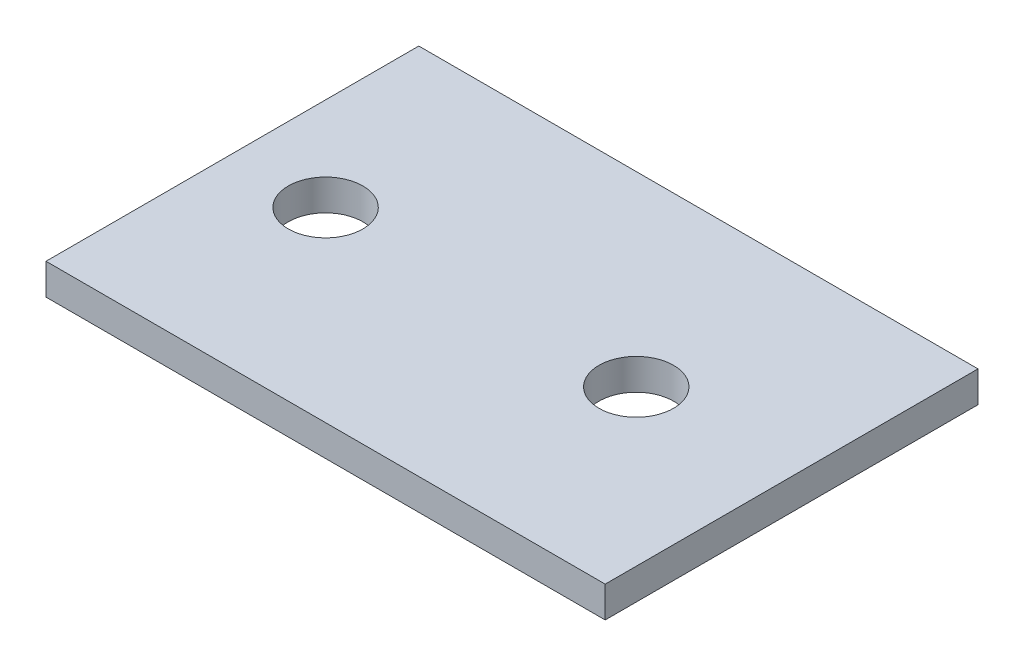
from build123d import *

# Parameters (mm, degrees)
SKETCH4_W           = 90
SKETCH4_H           = 60
SKETCH4_R           = 6
BOSS_EXTRUDE1_DEPTH = 2.5


with BuildPart() as part:
    # Sketch4 → Boss-Extrude1 (new body, symmetric)
    with BuildSketch(Plane(origin=(0, 0, 0), x_dir=(1, 0, 0), z_dir=(0, 1, 0))):
        Rectangle(SKETCH4_W, SKETCH4_H)
        with Locations((-30, 0)):
            Circle(SKETCH4_R, mode=Mode.SUBTRACT)
        with Locations((20, 0)):
            Circle(SKETCH4_R, mode=Mode.SUBTRACT)
    extrude(amount=BOSS_EXTRUDE1_DEPTH, both=True)


solid = part.part
